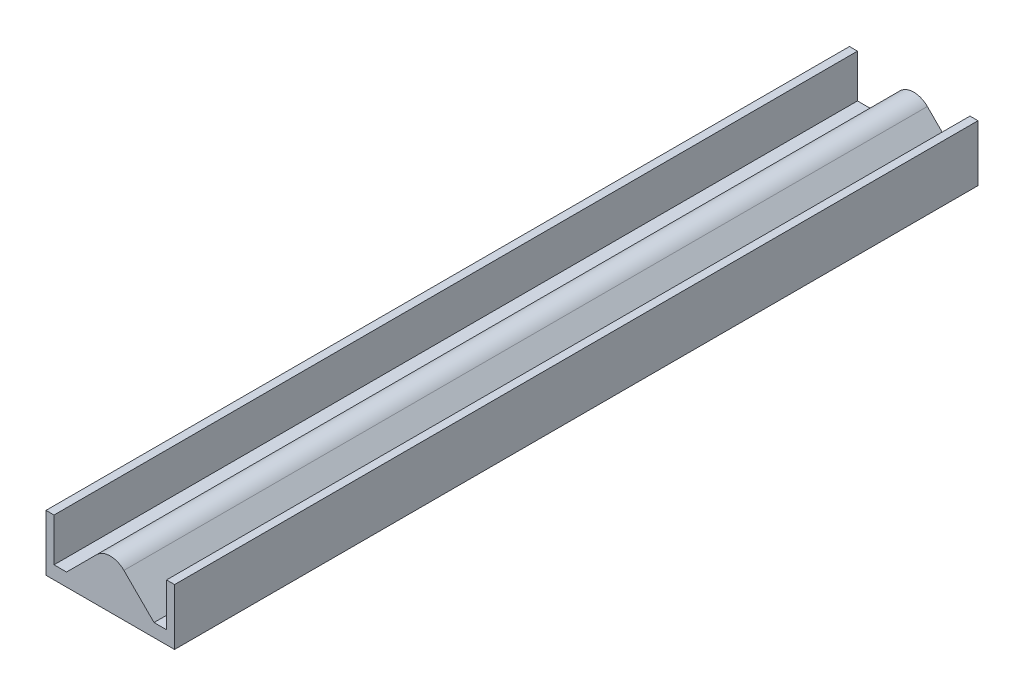
from build123d import *

# Parameters (mm, degrees)
BOSS_EXTRUDE1_DEPTH = 500
FILLET1_R           = 12


with BuildPart() as part:
    # Sketch1 → Boss-Extrude1 (new body)
    with BuildSketch(Plane.XY):
        Polygon((-40, 16.25), (-40, -18.75), (40, -18.75), (40, 16.25), (35, 16.25), (35, -10.594931419), (27.223611076, -10.594931419), (0, 16.628679656), (-27.223611076, -10.594931419), (-35, -10.594931419), (-35, 16.25), align=None)
    extrude(amount=BOSS_EXTRUDE1_DEPTH)

    # Fillet1
    fillet1_edges = [part.edges().sort_by_distance(p)[0] for p in [
        (0, 16.628679656, 250),
    ]]
    fillet(fillet1_edges, radius=FILLET1_R)


solid = part.part
